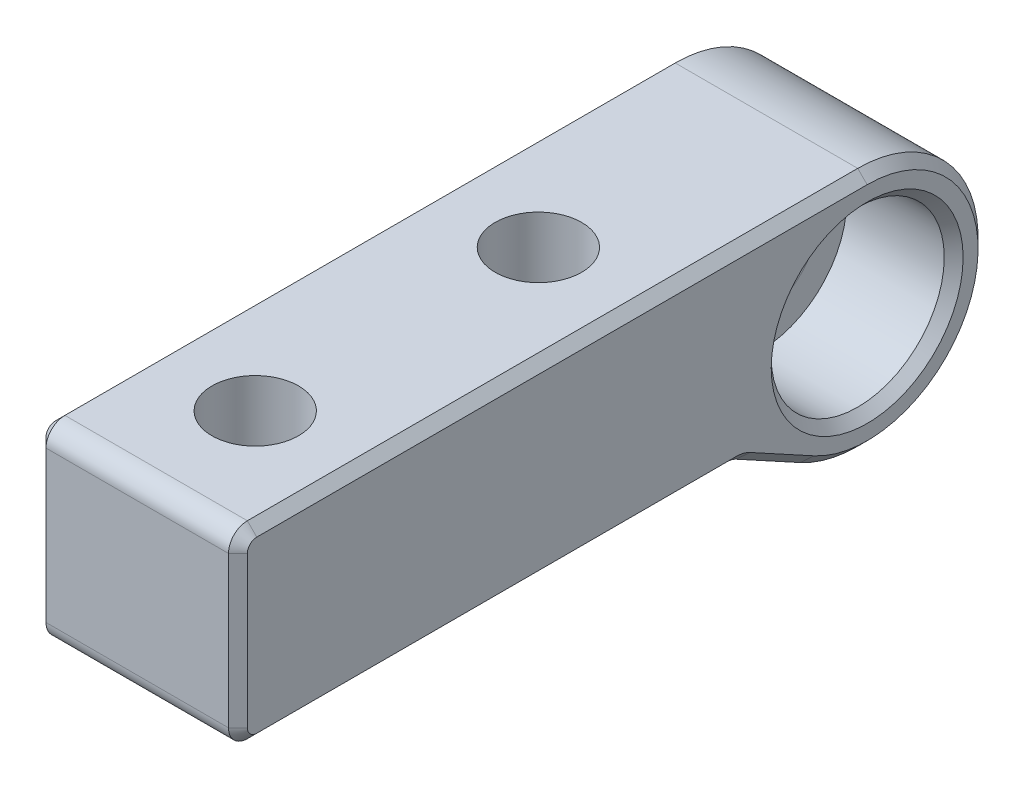
from build123d import *

# Parameters (mm, degrees)
SKETCH5_R                               = 3.15
BOSS_EXTRUDE5_DEPTH                     = 12.8
CBORE_FOR_M5_HEX_HEAD_BOLT1_D           = 5.5
CBORE_FOR_M5_HEX_HEAD_BOLT1_CBORE_D     = 10
CBORE_FOR_M5_HEX_HEAD_BOLT1_CBORE_DEPTH = 5.5
SKETCH8_R                               = 5.5
CUT_EXTRUDE_LEFT_DEPTH                  = 6.8
FILLET5_R                               = 1.2
CHAMFER2_SIZE                           = 0.6
FILLET7_R                               = 0.5


with BuildPart() as part:
    # Sketch5 → Boss-Extrude5 (new body)
    with BuildSketch(Plane(origin=(0, 0, 0), x_dir=(0, -1, 0), z_dir=(1, 0, 0))):
        with BuildLine():
            Line((-7.65, 0), (-7.65, -40))
            Line((-7.65, -40), (4.35, -40))
            Line((4.35, -40), (4.35, -8))
            Line((4.35, -8), (6.715651055, -3.663677239))
            ThreePointArc((6.715651055, -3.663677239), (7.412733321, -1.890472088), (7.65, 0))
            ThreePointArc((7.65, 0), (0, 7.65), (-7.65, 0))
        make_face()
        Circle(SKETCH5_R, mode=Mode.SUBTRACT)
    extrude(amount=BOSS_EXTRUDE5_DEPTH)

    # CBORE for M5 Hex Head Bolt1 (through all)
    with Locations(Plane(origin=(0, -4.35, 0), x_dir=(-1, 0, 0), z_dir=(0, -1, 0))):
        with Locations((-6.4, -14.5), (-6.4, -32.5)):
            CounterBoreHole(CBORE_FOR_M5_HEX_HEAD_BOLT1_D / 2, CBORE_FOR_M5_HEX_HEAD_BOLT1_CBORE_D / 2, CBORE_FOR_M5_HEX_HEAD_BOLT1_CBORE_DEPTH)

    # Sketch8 → Cut-Extrude-LEFT (cut)
    with BuildSketch(Plane(origin=(12.8, 0, 0), x_dir=(0, 0, -1), z_dir=(1, 0, 0))):
        Circle(SKETCH8_R)
    extrude(amount=-CUT_EXTRUDE_LEFT_DEPTH, mode=Mode.SUBTRACT)

    # Fillet5
    fillet5_edges = [part.edges().sort_by_distance(p)[0] for p in [
        (6.4, -4.35, 40),
        (6.4, 7.65, 40),
        (6.4, -4.35, 8),
    ]]
    fillet(fillet5_edges, radius=FILLET5_R)

    # Chamfer2
    chamfer2_edges = [part.edges().sort_by_distance(p)[0] for p in [
        (12.8, -1.890472088, -7.412733321),
        (0, 3.15, 0),
        (12.8, 7.65, 19.4),
        (12.8, 0, 5.5),
        (0, -5.606107798, 5.697509604),
        (12.8, -5.606107798, 5.697509604),
        (0, -4.35, 23.553018219),
        (12.8, -4.35, 23.553018219),
        (0, 1.65, 40),
        (12.8, 1.65, 40),
        (0, -3.998528137, 39.648528137),
        (0, 7.298528137, 39.648528137),
        (12.8, -3.998528137, 39.648528137),
        (12.8, 7.298528137, 39.648528137),
        (0, -4.387218303, 8.009491797),
        (12.8, -4.387218303, 8.009491797),
        (0, 7.65, 19.4),
        (0, -1.890472088, -7.412733321),
    ]]
    chamfer(chamfer2_edges, length=CHAMFER2_SIZE)

    # Fillet7
    fillet7_edges = [part.edges().sort_by_distance(p)[0] for p in [
        (6, 3.15, 0),
    ]]
    fillet(fillet7_edges, radius=FILLET7_R)


solid = part.part
